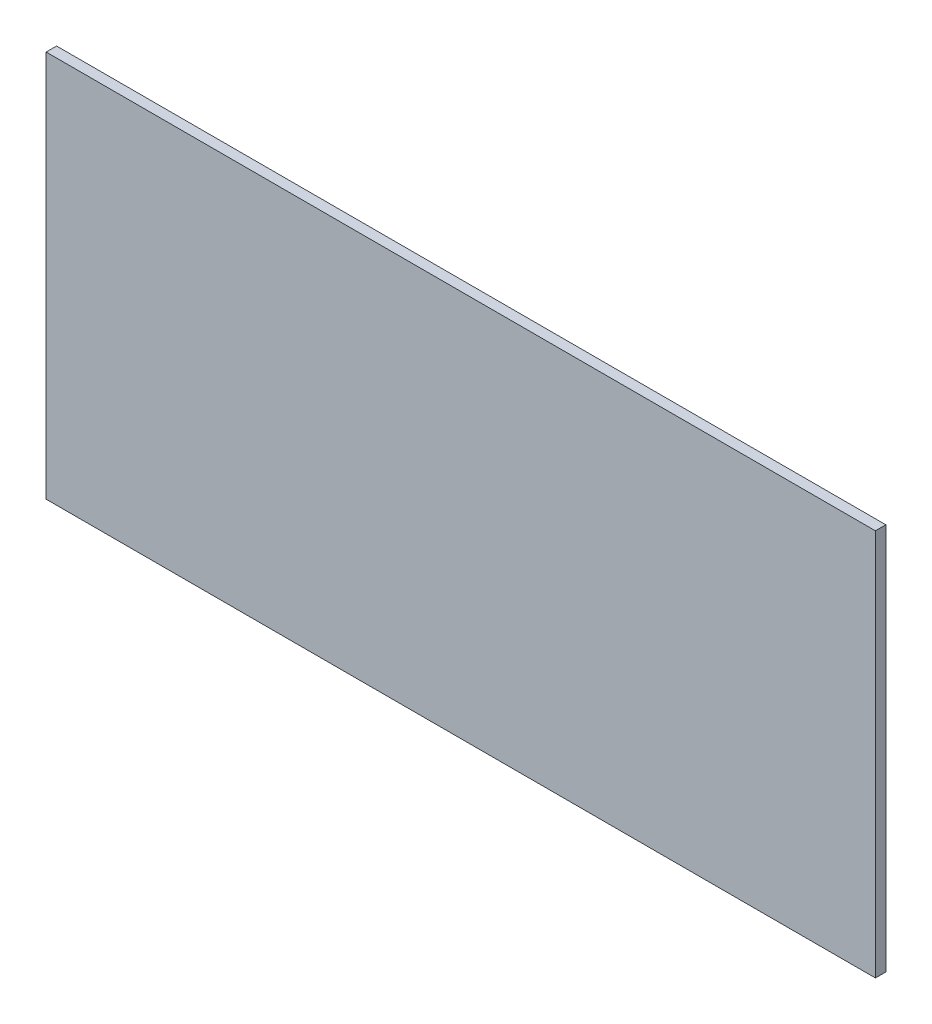
from build123d import *

# Parameters (mm, degrees)
SKETCH1_W           = 946.658829024
SKETCH1_H           = 442.11875
BOSS_EXTRUDE1_DEPTH = 11.90625


with BuildPart() as part:
    # Sketch1 → Boss-Extrude1 (new body)
    with BuildSketch(Plane.XY):
        with Locations((0, 232.965625)):
            Rectangle(SKETCH1_W, SKETCH1_H)
    extrude(amount=-BOSS_EXTRUDE1_DEPTH)


solid = part.part
